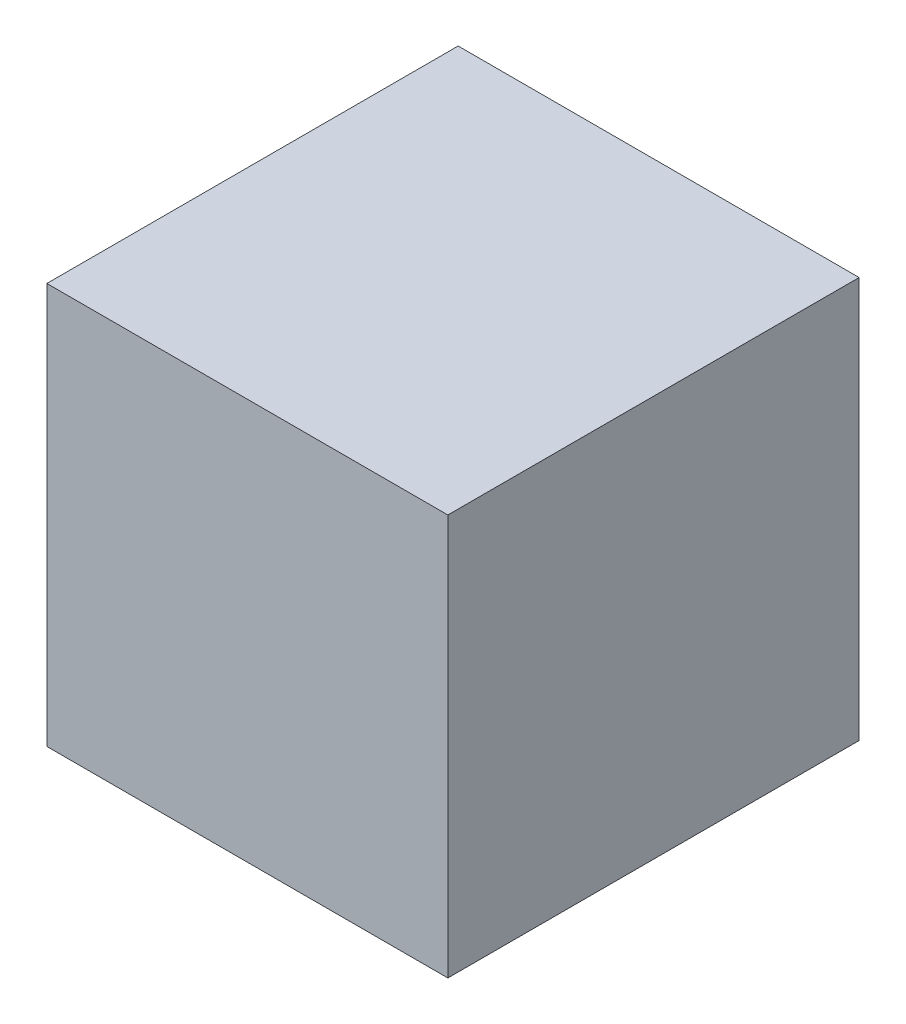
from build123d import *

# Parameters (mm, degrees)
Y_KSEKLIK_EKSTR_ZYON1_DEPTH      = 5.08
Y_KSEKLIK_EKSTR_ZYON1_DEPTH_BACK = 5.08
IZIM1_W                          = 9.906
IZIM1_H                          = 9.906


with BuildPart() as part:
    # Çizim1 → Yükseklik-Ekstrüzyon1 (new, two sides: drawn at the far end of the back side and taken through both)
    with BuildSketch(Plane.XY.offset(-Y_KSEKLIK_EKSTR_ZYON1_DEPTH_BACK)):
        Rectangle(IZIM1_W, IZIM1_H)
    extrude(amount=Y_KSEKLIK_EKSTR_ZYON1_DEPTH + Y_KSEKLIK_EKSTR_ZYON1_DEPTH_BACK)


solid = part.part
